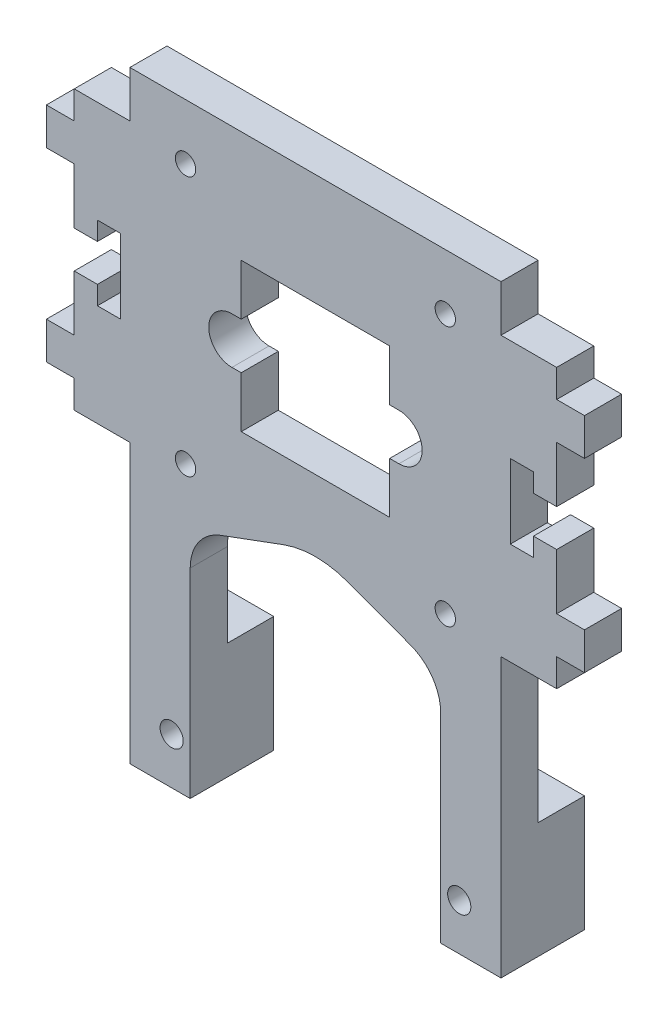
from build123d import *

# Parameters (mm, degrees)
SKETCH_1_W           = 58
SKETCH_1_H           = 30
EXTRUDE_1_DEPTH      = 4
SKETCH_2_W           = 4
SKETCH_2_H           = 3
SKETCH_2_H_2         = 6
SKETCH_2_H_3         = 4
CUT_EXTRUDE_2_DEPTH  = 3
SKETCH_3_W           = 4
SKETCH_3_H           = 3
SKETCH_3_H_2         = 6
SKETCH_3_H_3         = 4
CUT_EXTRUDE_3_DEPTH  = 3
CUT_EXTRUDE_4_DEPTH  = 5
SKETCH_5_R           = 7.5
CUT_EXTRUDE_5_DEPTH  = 5
SKETCH_11_W          = 16
SKETCH_11_H          = 16
CUT_EXTRUDE_10_DEPTH = 10
SKETCH_12_W          = 40
SKETCH_12_H          = 5
EXTRUDE_2_DEPTH      = 4
SKETCH_13_R          = 2.5
EXTRUDE_3_DEPTH      = 2.5
SKETCH_14_R          = 1.1
CUT_EXTRUDE_11_DEPTH = 7.5
SKETCH_15_W          = 6.5
SKETCH_15_H          = 25
SKETCH_15_R          = 1.25
EXTRUDE_4_DEPTH      = 4
SKETCH_16_W          = 6.5
SKETCH_16_H          = 12.5
SKETCH_16_R          = 1.25
EXTRUDE_5_DEPTH      = 5
CUT_EXTRUDE_12_DEPTH = 5
FILLET_1_R           = 10
FILLET_2_R           = 5


with BuildPart() as part:
    # 草图1 → 凸台-拉伸1 (new body)
    with BuildSketch(Plane.XY):
        Rectangle(SKETCH_1_W, SKETCH_1_H)
    extrude(amount=EXTRUDE_1_DEPTH)

    # 草图2 → 切除-拉伸2 (cut)
    with BuildSketch(Plane(origin=(29, 0, 0), x_dir=(0, 0, -1), z_dir=(1, 0, 0))):
        with Locations((-2, 13.5)):
            Rectangle(SKETCH_2_W, SKETCH_2_H)
        with Locations((-2, 5)):
            Rectangle(SKETCH_2_W, SKETCH_2_H_2)
        with Locations((-2, 0)):
            Rectangle(SKETCH_2_W, SKETCH_2_H_3)
        with Locations((-2, -5)):
            Rectangle(SKETCH_2_W, SKETCH_2_H_2)
        with Locations((-2, -13.5)):
            Rectangle(SKETCH_2_W, SKETCH_2_H)
    extrude(amount=-CUT_EXTRUDE_2_DEPTH, mode=Mode.SUBTRACT)

    # 草图3 → 切除-拉伸3 (cut)
    with BuildSketch(Plane.ZY.offset(29)):
        with Locations((2, 13.5)):
            Rectangle(SKETCH_3_W, SKETCH_3_H)
        with Locations((2, 5)):
            Rectangle(SKETCH_3_W, SKETCH_3_H_2)
        with Locations((2, 0)):
            Rectangle(SKETCH_3_W, SKETCH_3_H_3)
        with Locations((2, -5)):
            Rectangle(SKETCH_3_W, SKETCH_3_H_2)
        with Locations((2, -13.5)):
            Rectangle(SKETCH_3_W, SKETCH_3_H)
    extrude(amount=-CUT_EXTRUDE_3_DEPTH, mode=Mode.SUBTRACT)

    # 草图4 → 切除-拉伸4 (cut, through all)
    with BuildSketch(Plane(origin=(0, 0, 0), x_dir=(-1, 0, 0), z_dir=(0, 0, -1))):
        Polygon((-26, 2), (-23.5, 2), (-23.5, 4), (-21, 4), (-21, -4), (-23.5, -4), (-23.5, -2), (-26, -2), align=None)
        Polygon((26, -2), (23.5, -2), (23.5, -4), (21, -4), (21, 4), (23.5, 4), (23.5, 2), (26, 2), align=None)
    extrude(amount=-CUT_EXTRUDE_4_DEPTH, mode=Mode.SUBTRACT)

    # 草图5 → 切除-拉伸5 (cut, through all)
    with BuildSketch(Plane(origin=(0, 0, 0), x_dir=(-1, 0, 0), z_dir=(0, 0, -1))):
        Circle(SKETCH_5_R)
        with BuildLine():
            Line((-9, 2.5), (9, 2.5))
            ThreePointArc((9, 2.5), (11.5, 0), (9, -2.5))
            Line((9, -2.5), (-9, -2.5))
            ThreePointArc((-9, -2.5), (-11.5, 0), (-9, 2.5))
        make_face()
    extrude(amount=-CUT_EXTRUDE_5_DEPTH, mode=Mode.SUBTRACT)

    # 草图11 → 切除-拉伸10 (cut)
    with BuildSketch(Plane.XY.offset(4)):
        Rectangle(SKETCH_11_W, SKETCH_11_H)
    extrude(amount=-CUT_EXTRUDE_10_DEPTH, mode=Mode.SUBTRACT)

    # 草图12 → 凸台-拉伸2 (add)
    with BuildSketch(Plane(origin=(0, 0, 0), x_dir=(-1, 0, 0), z_dir=(0, 0, -1))):
        with Locations((0, 17.5)):
            Rectangle(SKETCH_12_W, SKETCH_12_H)
        with Locations((0, -17.5)):
            Rectangle(SKETCH_12_W, SKETCH_12_H)
    extrude(amount=-EXTRUDE_2_DEPTH)

    # 草图13 → 凸台-拉伸3 (add)
    with BuildSketch(Plane(origin=(0, 0, 0), x_dir=(-1, 0, 0), z_dir=(0, 0, -1))):
        with Locations((14, -14)):
            Circle(SKETCH_13_R)
        with Locations((-14, -14)):
            Circle(SKETCH_13_R)
        with Locations((14, 14)):
            Circle(SKETCH_13_R)
        with Locations((-14, 14)):
            Circle(SKETCH_13_R)
    extrude(amount=EXTRUDE_3_DEPTH)

    # 草图14 → 切除-拉伸11 (cut, through all)
    with BuildSketch(Plane(origin=(0, 0, -2.5), x_dir=(-1, 0, 0), z_dir=(0, 0, -1))):
        with Locations((14, -14)):
            Circle(SKETCH_14_R)
        with Locations((-14, -14)):
            Circle(SKETCH_14_R)
        with Locations((-14, 14)):
            Circle(SKETCH_14_R)
        with Locations((14, 14)):
            Circle(SKETCH_14_R)
    extrude(amount=-CUT_EXTRUDE_11_DEPTH, mode=Mode.SUBTRACT)

    # 草图15 → 凸台-拉伸4 (add)
    with BuildSketch(Plane(origin=(0, 0, 0), x_dir=(-1, 0, 0), z_dir=(0, 0, -1))):
        with Locations((16.75, -32.5)):
            Rectangle(SKETCH_15_W, SKETCH_15_H)
        with Locations((15.5, -40)):
            Circle(SKETCH_15_R, mode=Mode.SUBTRACT)
        with Locations((-16.75, -32.5)):
            Rectangle(SKETCH_15_W, SKETCH_15_H)
        with Locations((-15.5, -40)):
            Circle(SKETCH_15_R, mode=Mode.SUBTRACT)
    extrude(amount=-EXTRUDE_4_DEPTH)

    # 草图16 → 凸台-拉伸5 (add)
    with BuildSketch(Plane(origin=(0, 0, 0), x_dir=(-1, 0, 0), z_dir=(0, 0, -1))):
        with Locations((16.75, -38.75)):
            Rectangle(SKETCH_16_W, SKETCH_16_H)
        with Locations((15.5, -40)):
            Circle(SKETCH_16_R, mode=Mode.SUBTRACT)
        with Locations((-16.75, -38.75)):
            Rectangle(SKETCH_16_W, SKETCH_16_H)
        with Locations((-15.5, -40)):
            Circle(SKETCH_16_R, mode=Mode.SUBTRACT)
    extrude(amount=EXTRUDE_5_DEPTH)

    # 草图17 → 切除-拉伸12 (cut, through all)
    with BuildSketch(Plane(origin=(0, 0, 0), x_dir=(-1, 0, 0), z_dir=(0, 0, -1))):
        Polygon((13.5, -20), (0, -15), (-13.5, -20), align=None)
    extrude(amount=-CUT_EXTRUDE_12_DEPTH, mode=Mode.SUBTRACT)

    # 圆角1
    fillet_1_edges = [part.edges().sort_by_distance(p)[0] for p in [
        (0, -15, 2),
    ]]
    fillet(fillet_1_edges, radius=FILLET_1_R)

    # 圆角2
    fillet_2_edges = [part.edges().sort_by_distance(p)[0] for p in [
        (13.5, -20, 2),
        (-13.5, -20, 2),
    ]]
    fillet(fillet_2_edges, radius=FILLET_2_R)


solid = part.part
